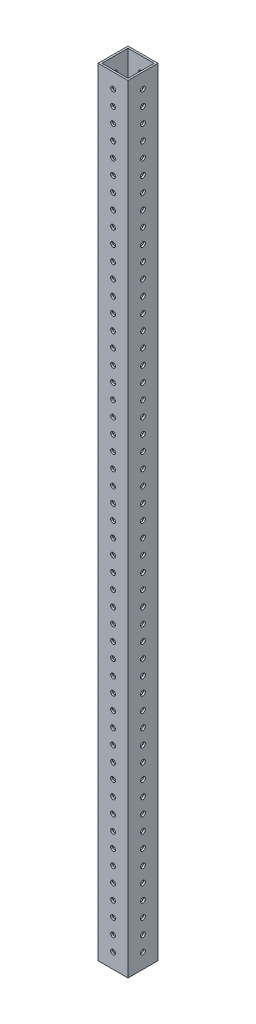
from build123d import *

# Parameters (mm, degrees)
SKETCH1_W           = 25.4
SKETCH1_H           = 25.4
SKETCH1_W_2         = 22.225
SKETCH1_H_2         = 22.225
BOSS_EXTRUDE1_DEPTH = 660.4
SKETCH2_R           = 2.0193
CUT_EXTRUDE1_DEPTH  = 26.4
SKETCH3_R           = 2.0193
CUT_EXTRUDE2_DEPTH  = 26.4


with BuildPart() as part:
    # Sketch1 → Boss-Extrude1 (new body)
    with BuildSketch(Plane(origin=(0, 0, 0), x_dir=(1, 0, 0), z_dir=(0, 1, 0))):
        with Locations((12.7, 12.7)):
            Rectangle(SKETCH1_W, SKETCH1_H)
        with Locations((12.7, 12.7)):
            Rectangle(SKETCH1_W_2, SKETCH1_H_2, mode=Mode.SUBTRACT)
    extrude(amount=BOSS_EXTRUDE1_DEPTH)

    # Sketch2 → Cut-Extrude1 (cut, through all)
    with BuildSketch(Plane.XY):
        with Locations((12.7, 12.7)):
            Circle(SKETCH2_R)
        with Locations((12.7, 25.4)):
            Circle(SKETCH2_R)
        with Locations((12.7, 38.1)):
            Circle(SKETCH2_R)
        with Locations((12.7, 50.8)):
            Circle(SKETCH2_R)
        with Locations((12.7, 63.5)):
            Circle(SKETCH2_R)
        with Locations((12.7, 76.2)):
            Circle(SKETCH2_R)
        with Locations((12.7, 88.9)):
            Circle(SKETCH2_R)
        with Locations((12.7, 101.6)):
            Circle(SKETCH2_R)
        with Locations((12.7, 114.3)):
            Circle(SKETCH2_R)
        with Locations((12.7, 127)):
            Circle(SKETCH2_R)
        with Locations((12.7, 139.7)):
            Circle(SKETCH2_R)
        with Locations((12.7, 152.4)):
            Circle(SKETCH2_R)
        with Locations((12.7, 165.1)):
            Circle(SKETCH2_R)
        with Locations((12.7, 177.8)):
            Circle(SKETCH2_R)
        with Locations((12.7, 190.5)):
            Circle(SKETCH2_R)
        with Locations((12.7, 203.2)):
            Circle(SKETCH2_R)
        with Locations((12.7, 215.9)):
            Circle(SKETCH2_R)
        with Locations((12.7, 228.6)):
            Circle(SKETCH2_R)
        with Locations((12.7, 241.3)):
            Circle(SKETCH2_R)
        with Locations((12.7, 254)):
            Circle(SKETCH2_R)
        with Locations((12.7, 266.7)):
            Circle(SKETCH2_R)
        with Locations((12.7, 279.4)):
            Circle(SKETCH2_R)
        with Locations((12.7, 292.1)):
            Circle(SKETCH2_R)
        with Locations((12.7, 304.8)):
            Circle(SKETCH2_R)
        with Locations((12.7, 317.5)):
            Circle(SKETCH2_R)
        with Locations((12.7, 330.2)):
            Circle(SKETCH2_R)
        with Locations((12.7, 342.9)):
            Circle(SKETCH2_R)
        with Locations((12.7, 355.6)):
            Circle(SKETCH2_R)
        with Locations((12.7, 368.3)):
            Circle(SKETCH2_R)
        with Locations((12.7, 381)):
            Circle(SKETCH2_R)
        with Locations((12.7, 393.7)):
            Circle(SKETCH2_R)
        with Locations((12.7, 406.4)):
            Circle(SKETCH2_R)
        with Locations((12.7, 419.1)):
            Circle(SKETCH2_R)
        with Locations((12.7, 431.8)):
            Circle(SKETCH2_R)
        with Locations((12.7, 444.5)):
            Circle(SKETCH2_R)
        with Locations((12.7, 457.2)):
            Circle(SKETCH2_R)
        with Locations((12.7, 469.9)):
            Circle(SKETCH2_R)
        with Locations((12.7, 482.6)):
            Circle(SKETCH2_R)
        with Locations((12.7, 495.3)):
            Circle(SKETCH2_R)
        with Locations((12.7, 508)):
            Circle(SKETCH2_R)
        with Locations((12.7, 520.7)):
            Circle(SKETCH2_R)
        with Locations((12.7, 533.4)):
            Circle(SKETCH2_R)
        with Locations((12.7, 546.1)):
            Circle(SKETCH2_R)
        with Locations((12.7, 558.8)):
            Circle(SKETCH2_R)
        with Locations((12.7, 571.5)):
            Circle(SKETCH2_R)
        with Locations((12.7, 584.2)):
            Circle(SKETCH2_R)
        with Locations((12.7, 596.9)):
            Circle(SKETCH2_R)
        with Locations((12.7, 609.6)):
            Circle(SKETCH2_R)
        with Locations((12.7, 622.3)):
            Circle(SKETCH2_R)
        with Locations((12.7, 635)):
            Circle(SKETCH2_R)
        with Locations((12.7, 647.7)):
            Circle(SKETCH2_R)
    extrude(amount=-CUT_EXTRUDE1_DEPTH, mode=Mode.SUBTRACT)

    # Sketch3 → Cut-Extrude2 (cut, through all)
    with BuildSketch(Plane(origin=(25.4, 0, 0), x_dir=(0, 0, -1), z_dir=(1, 0, 0))):
        with Locations((12.7, 12.7)):
            Circle(SKETCH3_R)
        with Locations((12.7, 25.4)):
            Circle(SKETCH3_R)
        with Locations((12.7, 38.1)):
            Circle(SKETCH3_R)
        with Locations((12.7, 50.8)):
            Circle(SKETCH3_R)
        with Locations((12.7, 63.5)):
            Circle(SKETCH3_R)
        with Locations((12.7, 76.2)):
            Circle(SKETCH3_R)
        with Locations((12.7, 88.9)):
            Circle(SKETCH3_R)
        with Locations((12.7, 101.6)):
            Circle(SKETCH3_R)
        with Locations((12.7, 114.3)):
            Circle(SKETCH3_R)
        with Locations((12.7, 127)):
            Circle(SKETCH3_R)
        with Locations((12.7, 139.7)):
            Circle(SKETCH3_R)
        with Locations((12.7, 152.4)):
            Circle(SKETCH3_R)
        with Locations((12.7, 165.1)):
            Circle(SKETCH3_R)
        with Locations((12.7, 177.8)):
            Circle(SKETCH3_R)
        with Locations((12.7, 190.5)):
            Circle(SKETCH3_R)
        with Locations((12.7, 203.2)):
            Circle(SKETCH3_R)
        with Locations((12.7, 215.9)):
            Circle(SKETCH3_R)
        with Locations((12.7, 228.6)):
            Circle(SKETCH3_R)
        with Locations((12.7, 241.3)):
            Circle(SKETCH3_R)
        with Locations((12.7, 254)):
            Circle(SKETCH3_R)
        with Locations((12.7, 266.7)):
            Circle(SKETCH3_R)
        with Locations((12.7, 279.4)):
            Circle(SKETCH3_R)
        with Locations((12.7, 292.1)):
            Circle(SKETCH3_R)
        with Locations((12.7, 304.8)):
            Circle(SKETCH3_R)
        with Locations((12.7, 317.5)):
            Circle(SKETCH3_R)
        with Locations((12.7, 330.2)):
            Circle(SKETCH3_R)
        with Locations((12.7, 342.9)):
            Circle(SKETCH3_R)
        with Locations((12.7, 355.6)):
            Circle(SKETCH3_R)
        with Locations((12.7, 368.3)):
            Circle(SKETCH3_R)
        with Locations((12.7, 381)):
            Circle(SKETCH3_R)
        with Locations((12.7, 393.7)):
            Circle(SKETCH3_R)
        with Locations((12.7, 406.4)):
            Circle(SKETCH3_R)
        with Locations((12.7, 419.1)):
            Circle(SKETCH3_R)
        with Locations((12.7, 431.8)):
            Circle(SKETCH3_R)
        with Locations((12.7, 444.5)):
            Circle(SKETCH3_R)
        with Locations((12.7, 457.2)):
            Circle(SKETCH3_R)
        with Locations((12.7, 469.9)):
            Circle(SKETCH3_R)
        with Locations((12.7, 482.6)):
            Circle(SKETCH3_R)
        with Locations((12.7, 495.3)):
            Circle(SKETCH3_R)
        with Locations((12.7, 508)):
            Circle(SKETCH3_R)
        with Locations((12.7, 520.7)):
            Circle(SKETCH3_R)
        with Locations((12.7, 533.4)):
            Circle(SKETCH3_R)
        with Locations((12.7, 546.1)):
            Circle(SKETCH3_R)
        with Locations((12.7, 558.8)):
            Circle(SKETCH3_R)
        with Locations((12.7, 571.5)):
            Circle(SKETCH3_R)
        with Locations((12.7, 584.2)):
            Circle(SKETCH3_R)
        with Locations((12.7, 596.9)):
            Circle(SKETCH3_R)
        with Locations((12.7, 609.6)):
            Circle(SKETCH3_R)
        with Locations((12.7, 622.3)):
            Circle(SKETCH3_R)
        with Locations((12.7, 635)):
            Circle(SKETCH3_R)
        with Locations((12.7, 647.7)):
            Circle(SKETCH3_R)
    extrude(amount=-CUT_EXTRUDE2_DEPTH, mode=Mode.SUBTRACT)


solid = part.part
